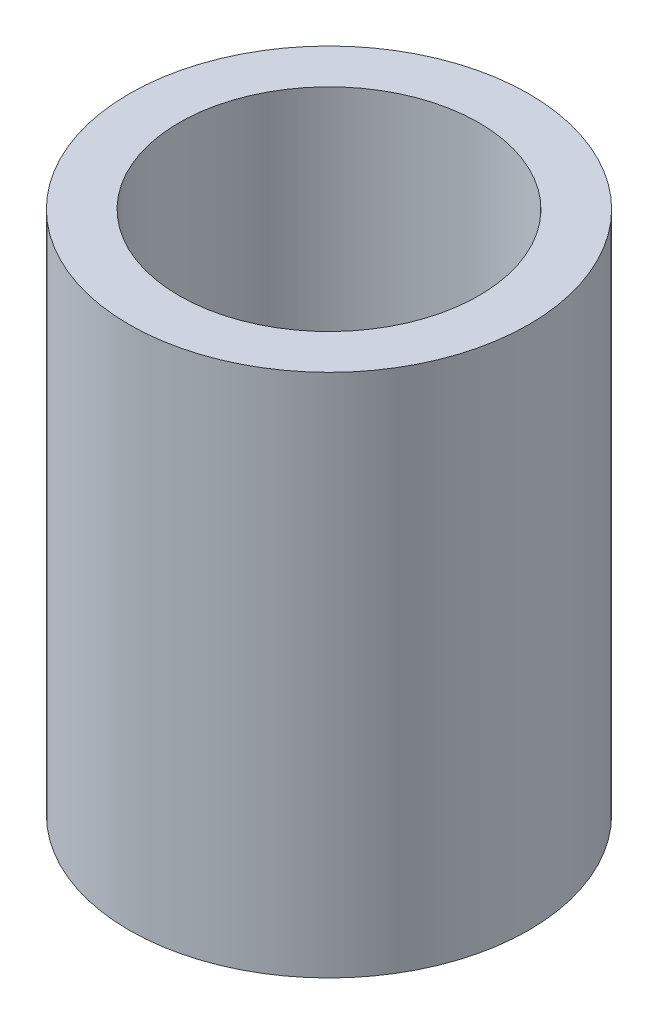
from build123d import *

# Parameters (mm, degrees)
SKETCH1_W = 8
SKETCH1_H = 83.984026871


with BuildPart() as part:
    # Sketch1 → Revolve1 (revolve)
    with BuildSketch(Plane.XY):
        with Locations((-28, 41.992013436)):
            Rectangle(SKETCH1_W, SKETCH1_H)
    revolve(axis=Axis((0, 0, 0), (0, 1, 0)))


solid = part.part
